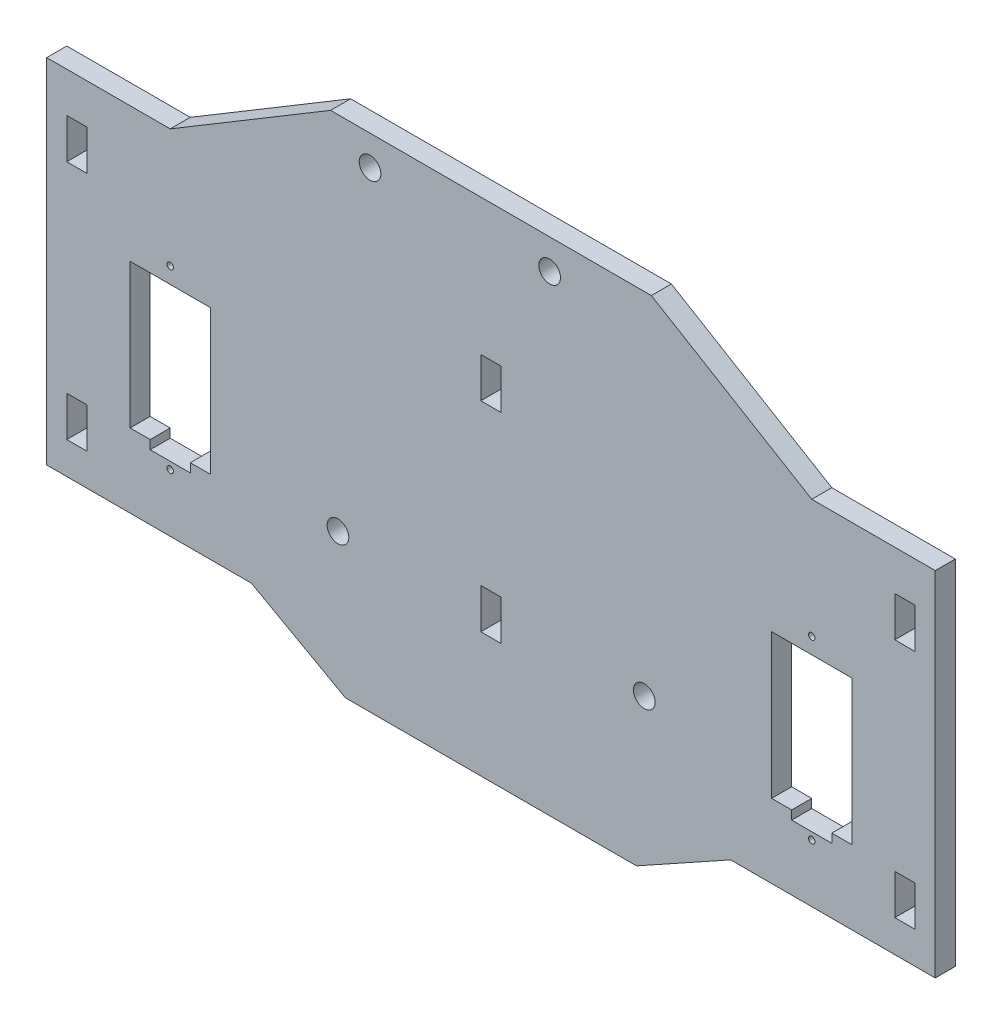
from build123d import *

# Parameters (mm, degrees)
SKETCH1_W                          = 140.716
SKETCH1_H                          = 55.88
BOSS_EXTRUDE1_DEPTH                = 3.175
SKETCH2_W                          = 3.2258
SKETCH2_H                          = 6.35
HOLES_FOR_TABS_DEPTH               = 4.175
SKETCH3_W                          = 3.2258
SKETCH3_H                          = 6.35
CUT_FOR_TABS_NOSEPANEL_DEPTH       = 4.175
SKETCH5_R                          = 0.508
CUT_FOR_OPTIONAL_MOTORS_EARS_DEPTH = 4.175
BOSS_EXTRUDE2_DEPTH                = 3.175
SKETCH7_R                          = 1.7145
CUT_FOR_ARDUINO_MOUNT_HOLES_DEPTH  = 4.175


with BuildPart() as part:
    # Sketch1 → Boss-Extrude1 (new body)
    with BuildSketch(Plane.XY):
        Rectangle(SKETCH1_W, SKETCH1_H)
    extrude(amount=BOSS_EXTRUDE1_DEPTH)

    # Sketch2 → holes for tabs (cut, through all)
    with BuildSketch(Plane.XY.offset(3.175)):
        with Locations((-65.5701, 18.415)):
            Rectangle(SKETCH2_W, SKETCH2_H)
        with Locations((-65.5701, -19.685)):
            Rectangle(SKETCH2_W, SKETCH2_H)
    holes_for_tabs = extrude(amount=-HOLES_FOR_TABS_DEPTH, mode=Mode.SUBTRACT)

    # Mirror1: holes for tabs across plane
    add(holes_for_tabs.mirror(Plane(origin=(0, 0, 0), x_dir=(0, 0, 1), z_dir=(1, 0, 0))), mode=Mode.SUBTRACT)

    # Sketch3 → cut for tabs, nosepanel (cut, through all)
    with BuildSketch(Plane.XY.offset(3.175)):
        with Locations((0, 18.415547881)):
            Rectangle(SKETCH3_W, SKETCH3_H)
        with Locations((0, -13.264075424)):
            Rectangle(SKETCH3_W, SKETCH3_H)
    extrude(amount=-CUT_FOR_TABS_NOSEPANEL_DEPTH, mode=Mode.SUBTRACT)

    # Sketch5 → cut for optional motors (ears) (cut, through all)
    with BuildSketch(Plane.XY.offset(3.175)):
        with Locations((-50.8, -18.796)):
            Circle(SKETCH5_R)
        with Locations((-50.8, 9.144)):
            Circle(SKETCH5_R)
        Polygon((-44.45, 6.604), (-57.15, 6.604), (-57.15, -16.256), (-53.975, -16.256), (-53.975, -17.653), (-47.625, -17.653), (-47.625, -16.256), (-44.45, -16.256), align=None)
    cut_for_optional_motors_ears = extrude(amount=-CUT_FOR_OPTIONAL_MOTORS_EARS_DEPTH, mode=Mode.SUBTRACT)

    # Mirror2: cut for optional motors (ears) across plane
    add(cut_for_optional_motors_ears.mirror(Plane(origin=(0, 0, 0), x_dir=(0, 0, 1), z_dir=(1, 0, 0))), mode=Mode.SUBTRACT)

    # Sketch6 → Boss-Extrude2 (add)
    with BuildSketch(Plane.XY.offset(3.175)):
        Polygon((0, -27.94), (0, -36.218644949), (-23.051937452, -36.218644949), (-37.953832941, -27.94), align=None)
        Polygon((0, 27.94), (0, 43.18), (-25.4, 43.18), (-50.8, 27.94), align=None)
    boss_extrude2 = extrude(amount=-BOSS_EXTRUDE2_DEPTH)

    # Mirror3: Boss-Extrude2 across plane
    add(boss_extrude2.mirror(Plane(origin=(0, 0, 0), x_dir=(0, 0, 1), z_dir=(1, 0, 0))))

    # Sketch7 → cut for arduino mount holes (cut, through all)
    with BuildSketch(Plane(origin=(0, 0, 0), x_dir=(-1, 0, 0), z_dir=(0, 0, -1))):
        with Locations((19.154550283, 38.4302)):
            Circle(SKETCH7_R)
        with Locations((-9.293449717, 38.4302)):
            Circle(SKETCH7_R)
        with Locations((24.234550283, -13.97)):
            Circle(SKETCH7_R)
        with Locations((-24.279449717, -12.319)):
            Circle(SKETCH7_R)
    extrude(amount=-CUT_FOR_ARDUINO_MOUNT_HOLES_DEPTH, mode=Mode.SUBTRACT)


solid = part.part
